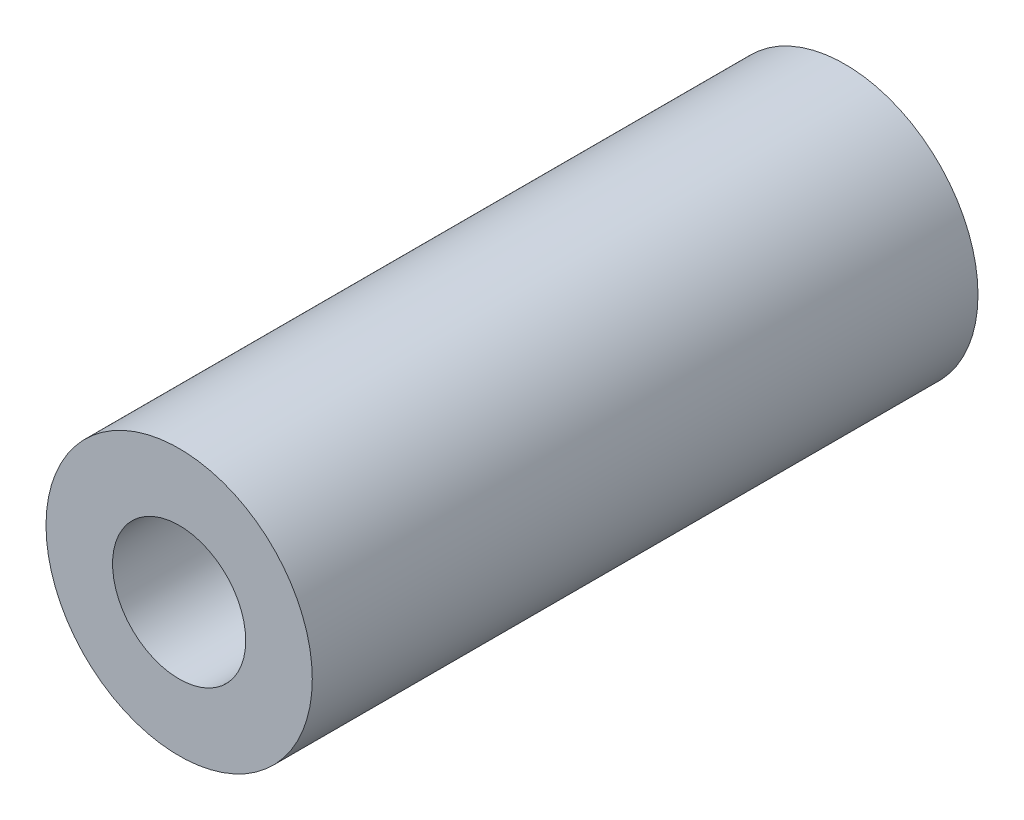
from build123d import *

# Parameters (mm, degrees)
SKETCH_1_R          = 8
EXTRUDE_1_DEPTH     = 20
SKETCH_2_R          = 4
CUT_EXTRUDE_1_DEPTH = 13


with BuildPart() as part:
    # 草图1 → 凸台-拉伸1 (new body)
    with BuildSketch(Plane.XY):
        Circle(SKETCH_1_R)
    extrude(amount=EXTRUDE_1_DEPTH)

    # 草图2 → 切除-拉伸1 (cut)
    with BuildSketch(Plane.XY.offset(20)):
        Circle(SKETCH_2_R)
    extrude(amount=-CUT_EXTRUDE_1_DEPTH, mode=Mode.SUBTRACT)

    # 镜向1: part across plane


with BuildPart() as part_1:
    add(part.part)
    add(part.part.mirror(Plane.XY))


solid = part_1.part
